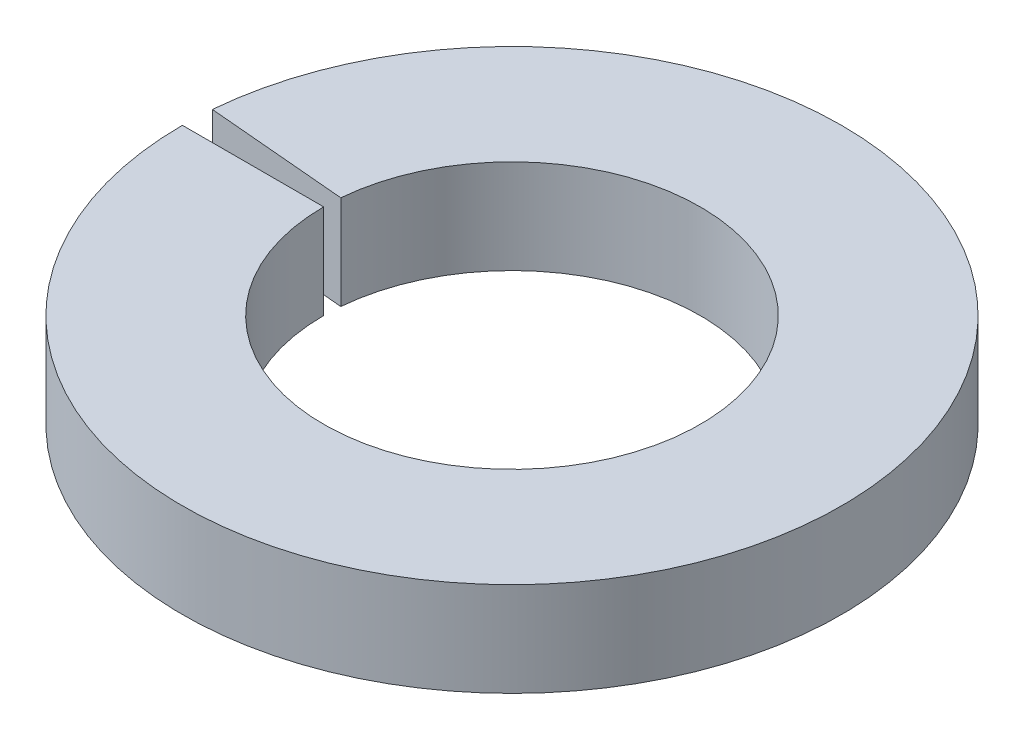
from build123d import *

# Parameters (mm, degrees)
SKETCH1_W      = 4.7625
SKETCH1_H      = 3.175
REVOLVE1_ANGLE = 355


with BuildPart() as part:
    # Sketch1 → Revolve1 (revolve)
    with BuildSketch(Plane.XY):
        with Locations((-8.73125, 1.5875)):
            Rectangle(SKETCH1_W, SKETCH1_H)
    revolve(axis=Axis((0, 0, 0), (0, 1, 0)), revolution_arc=REVOLVE1_ANGLE)


solid = part.part
